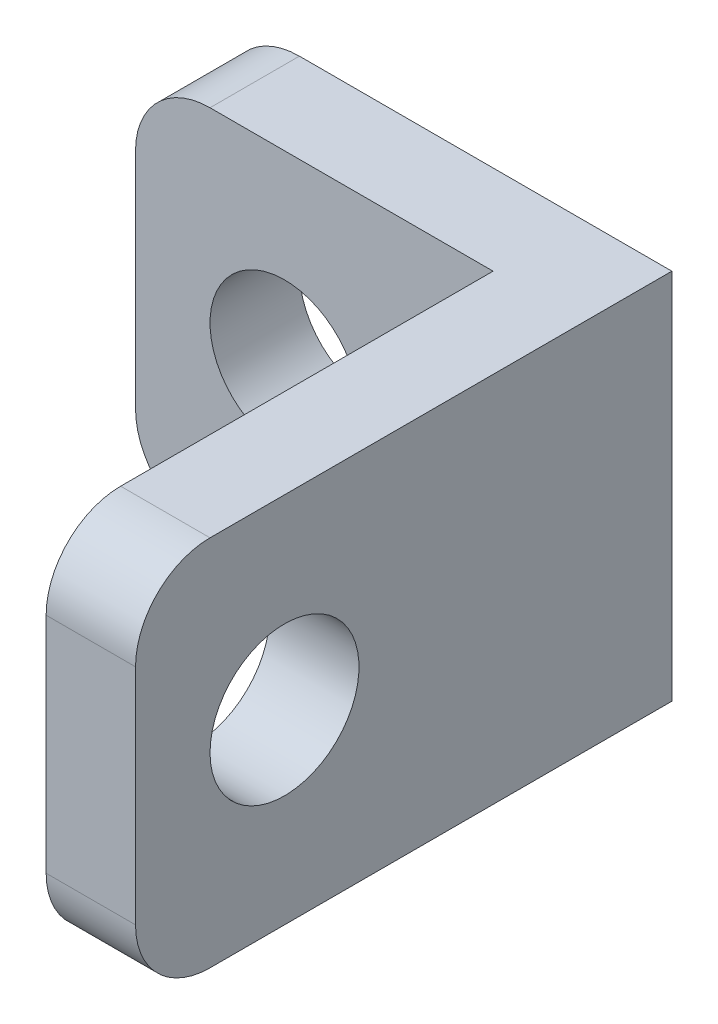
from build123d import *

# Parameters (mm, degrees)
SKETCH_1_R          = 1
EXTRUDE_1_DEPTH     = 1.2
SKETCH_2_W          = 1.2
SKETCH_2_H          = 5
EXTRUDE_2_DEPTH     = 6
FILLET_1_R          = 1
SKETCH_4_R          = 1
CUT_EXTRUDE_1_DEPTH = 2


with BuildPart() as part:
    # 草图1 → 凸台-拉伸1 (new body)
    with BuildSketch(Plane.XY):
        with BuildLine():
            Line((1, 0), (6, 0))
            Line((6, 0), (6, 5))
            Line((6, 5), (1, 5))
            ThreePointArc((1, 5), (0.292893219, 4.707106781), (0, 4))
            Line((0, 4), (0, 1))
            ThreePointArc((0, 1), (0.292893219, 0.292893219), (1, 0))
        make_face()
        with Locations((2, 2.5)):
            Circle(SKETCH_1_R, mode=Mode.SUBTRACT)
    extrude(amount=EXTRUDE_1_DEPTH)

    # 草图2 → 凸台-拉伸2 (add)
    with BuildSketch(Plane(origin=(0, 0, 1.2), x_dir=(-1, 0, 0), z_dir=(0, 0, -1))):
        with Locations((-5.4, 2.5)):
            Rectangle(SKETCH_2_W, SKETCH_2_H)
    extrude(amount=-EXTRUDE_2_DEPTH)

    # 圆角1
    fillet_1_edges = [part.edges().sort_by_distance(p)[0] for p in [
        (5.4, 0, 7.2),
        (5.4, 5, 7.2),
    ]]
    fillet(fillet_1_edges, radius=FILLET_1_R)

    # 草图4 → 切除-拉伸1 (cut)
    with BuildSketch(Plane.ZY.offset(-4.8)):
        with Locations((5.2, 2.5)):
            Circle(SKETCH_4_R)
    extrude(amount=-CUT_EXTRUDE_1_DEPTH, mode=Mode.SUBTRACT)


solid = part.part
